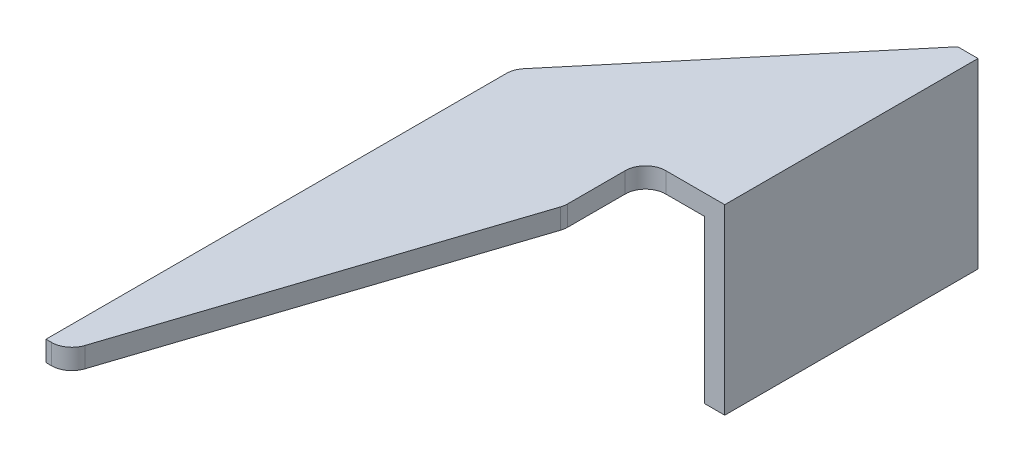
from build123d import *

# Parameters (mm, degrees)
EXTRUDE_THIN1_DEPTH = 70
CUT_EXTRUDE1_DEPTH  = 19
CUT_EXTRUDE2_DEPTH  = 19
FILLET1_R           = 2


with BuildPart() as part:
    # Sketch1 → Extrude-Thin1 (new body)
    with BuildSketch(Plane.XY):
        Polygon((0, 0), (0, 16), (-20, 16), (-20, 18), (2, 18), (2, 0), align=None)
    extrude(amount=EXTRUDE_THIN1_DEPTH)

    # Sketch2 → Cut-Extrude1 (cut, through all)
    with BuildSketch(Plane(origin=(0, 18, 0), x_dir=(1, 0, 0), z_dir=(0, 1, 0))):
        Polygon((2, -25), (-5.822, -25), (-5.822, -33), (-18, -70), (2, -70), align=None)
    extrude(amount=-CUT_EXTRUDE1_DEPTH, mode=Mode.SUBTRACT)

    # Sketch3 → Cut-Extrude2 (cut, through all)
    with BuildSketch(Plane(origin=(0, 18, 0), x_dir=(1, 0, 0), z_dir=(0, 1, 0))):
        Polygon((-20, -23.835071852), (0, 0), (-20, 0), align=None)
    extrude(amount=-CUT_EXTRUDE2_DEPTH, mode=Mode.SUBTRACT)

    # Fillet1
    fillet1_edges = [part.edges().sort_by_distance(p)[0] for p in [
        (-18, 17, 70),
        (-5.822, 17, 33),
        (-5.822, 17, 25),
        (-20, 17, 23.835071852),
    ]]
    fillet(fillet1_edges, radius=FILLET1_R)


solid = part.part
